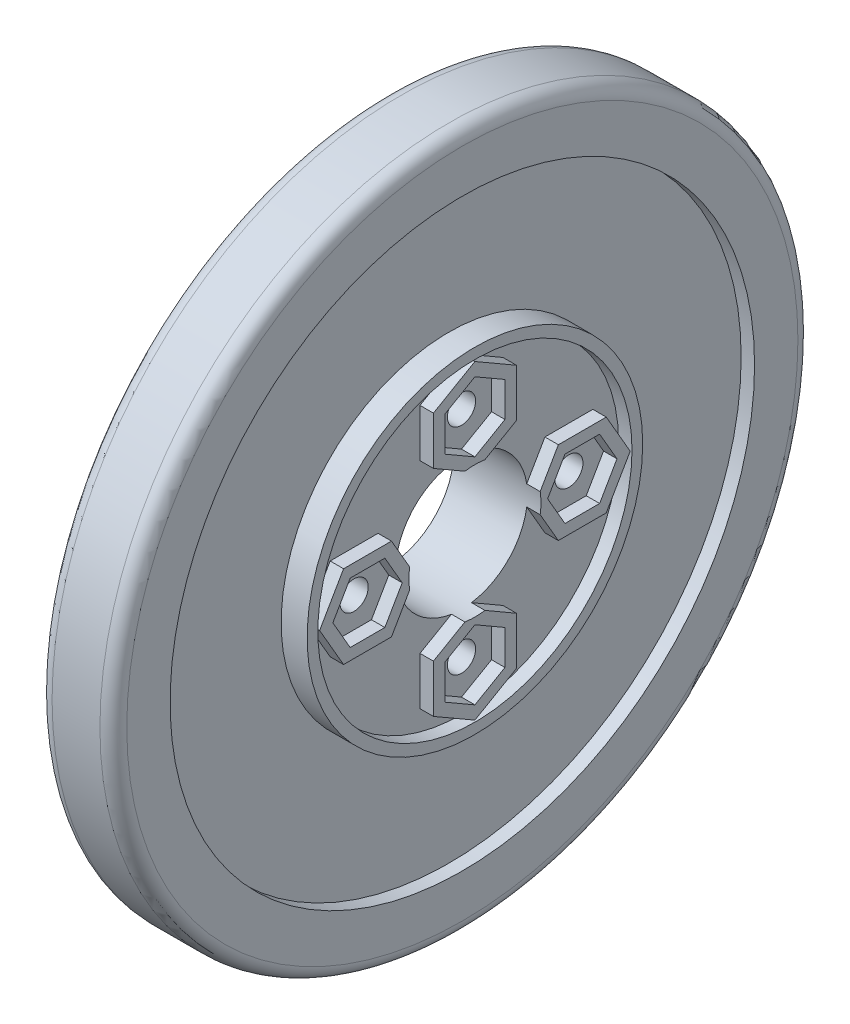
from build123d import *

# Parameters (mm, degrees)
FILLET1_R          = 1
SKETCH2_R          = 11.704122172
SKETCH2_R_2        = 1.05
CUT_EXTRUDE1_DEPTH = 1
SKETCH2_3_R        = 4.91900138
SKETCH2_3_R_2      = 1.05
CUT_EXTRUDE2_DEPTH = 38.339657272
SKETCH3_R          = 21.771584826
SKETCH3_R_2        = 12.5
CUT_EXTRUDE3_DEPTH = 1
CUT_EXTRUDE4_START = -1
SKETCH4_R          = 21.771584826
SKETCH4_R_2        = 12.5
CUT_EXTRUDE4_DEPTH = 1


with BuildPart() as part:
    # Sketch1 → Revolve1 (revolve)
    with BuildSketch(Plane(origin=(0, 0, 0), x_dir=(1, 0, 0), z_dir=(0, 1, 0))):
        Polygon((0, 0), (6.5, 0), (6.5, 12.5), (5.563387429, 12.5), (5.563387429, 26), (0, 26), align=None)
    revolve(axis=Axis((6.5, 0, 0), (-1, 0, 0)))

    # Fillet1
    fillet1_edges = [part.edges().sort_by_distance(p)[0] for p in [
        (0, 0, 26),
        (5.563387429, 0, 26),
    ]]
    fillet(fillet1_edges, radius=FILLET1_R)

    # Sketch2 → Cut-Extrude1 (cut)
    # profile 1 of 5: a face of its own
    with BuildSketch(Plane(origin=(6.5, 0, 0), x_dir=(0, 0, -1), z_dir=(1, 0, 0))):
        Circle(SKETCH2_R)
        with BuildLine():
            Line((6.215873313, -3.090198068), (4.862176877, -0.745527062))
            ThreePointArc((4.862176877, -0.745527062), (3.478259233, -3.478259233), (0.745527062, -4.862176877))
            Line((0.745527062, -4.862176877), (3.090198068, -6.215873313))
            Line((3.090198068, -6.215873313), (3.090198068, -9.784126687))
            Line((3.090198068, -9.784126687), (0, -11.568253373))
            Line((0, -11.568253373), (-3.090198068, -9.784126687))
            Line((-3.090198068, -9.784126687), (-3.090198068, -6.215873313))
            Line((-3.090198068, -6.215873313), (-0.745527062, -4.862176877))
            ThreePointArc((-0.745527062, -4.862176877), (-3.478259233, -3.478259233), (-4.862176877, -0.745527062))
            Line((-4.862176877, -0.745527062), (-6.215873313, -3.090198068))
            Line((-6.215873313, -3.090198068), (-9.784126687, -3.090198068))
            Line((-9.784126687, -3.090198068), (-11.568253373, 0))
            Line((-11.568253373, 0), (-9.784126687, 3.090198068))
            Line((-9.784126687, 3.090198068), (-6.215873313, 3.090198068))
            Line((-6.215873313, 3.090198068), (-4.862176877, 0.745527062))
            ThreePointArc((-4.862176877, 0.745527062), (-3.478259233, 3.478259233), (-0.745527062, 4.862176877))
            Line((-0.745527062, 4.862176877), (-3.090198068, 6.215873313))
            Line((-3.090198068, 6.215873313), (-3.090198068, 9.784126687))
            Line((-3.090198068, 9.784126687), (0, 11.568253373))
            Line((0, 11.568253373), (3.090198068, 9.784126687))
            Line((3.090198068, 9.784126687), (3.090198068, 6.215873313))
            Line((3.090198068, 6.215873313), (0.745527062, 4.862176877))
            ThreePointArc((0.745527062, 4.862176877), (3.478259233, 3.478259233), (4.862176877, 0.745527062))
            Line((4.862176877, 0.745527062), (6.215873313, 3.090198068))
            Line((6.215873313, 3.090198068), (9.784126687, 3.090198068))
            Line((9.784126687, 3.090198068), (11.568253373, 0))
            Line((11.568253373, 0), (9.784126687, -3.090198068))
            Line((9.784126687, -3.090198068), (6.215873313, -3.090198068))
        make_face(mode=Mode.SUBTRACT)
    # profile 2 of 5: a face of its own
    with BuildSketch(Plane(origin=(6.5, 0, 0), x_dir=(0, 0, -1), z_dir=(1, 0, 0))):
        Polygon((-2.237316109, 6.708284942), (0, 5.416569884), (2.237316109, 6.708284942), (2.237316109, 9.291715058), (0, 10.583430116), (-2.237316109, 9.291715058), align=None)
        with Locations((0, 8)):
            Circle(SKETCH2_R_2, mode=Mode.SUBTRACT)
    # profile 3 of 5: a face of its own
    with BuildSketch(Plane(origin=(6.5, 0, 0), x_dir=(0, 0, -1), z_dir=(1, 0, 0))):
        Polygon((-6.708284942, -2.237316109), (-5.416569884, 0), (-6.708284942, 2.237316109), (-9.291715058, 2.237316109), (-10.583430116, 0), (-9.291715058, -2.237316109), align=None)
        with Locations((-8, 0)):
            Circle(SKETCH2_R_2, mode=Mode.SUBTRACT)
    # profile 4 of 5: a face of its own
    with BuildSketch(Plane(origin=(6.5, 0, 0), x_dir=(0, 0, -1), z_dir=(1, 0, 0))):
        Polygon((6.708284942, 2.237316109), (5.416569884, 0), (6.708284942, -2.237316109), (9.291715058, -2.237316109), (10.583430116, 0), (9.291715058, 2.237316109), align=None)
        with Locations((8, 0)):
            Circle(SKETCH2_R_2, mode=Mode.SUBTRACT)
    # profile 5 of 5: a face of its own
    with BuildSketch(Plane(origin=(6.5, 0, 0), x_dir=(0, 0, -1), z_dir=(1, 0, 0))):
        Polygon((2.237316109, -6.708284942), (0, -5.416569884), (-2.237316109, -6.708284942), (-2.237316109, -9.291715058), (0, -10.583430116), (2.237316109, -9.291715058), align=None)
        with Locations((0, -8)):
            Circle(SKETCH2_R_2, mode=Mode.SUBTRACT)
    extrude(amount=-CUT_EXTRUDE1_DEPTH, mode=Mode.SUBTRACT)

    # Sketch2_3 → Cut-Extrude2 (cut, through all)
    with BuildSketch(Plane(origin=(6.5, 0, 0), x_dir=(0, 0, -1), z_dir=(1, 0, 0))):
        Circle(SKETCH2_3_R)
        with Locations((8, 0)):
            Circle(SKETCH2_3_R_2)
        with Locations((0, -8)):
            Circle(SKETCH2_3_R_2)
        with Locations((-8, 0)):
            Circle(SKETCH2_3_R_2)
        with Locations((0, 8)):
            Circle(SKETCH2_3_R_2)
    extrude(amount=-CUT_EXTRUDE2_DEPTH, mode=Mode.SUBTRACT)

    # Sketch3 → Cut-Extrude3 (cut)
    with BuildSketch(Plane.ZY):
        Circle(SKETCH3_R)
        Circle(SKETCH3_R_2, mode=Mode.SUBTRACT)
    extrude(amount=-CUT_EXTRUDE3_DEPTH, mode=Mode.SUBTRACT)

    # Sketch4 → Cut-Extrude4 (cut)
    with BuildSketch(Plane(origin=(5.563387429, 0, 0), x_dir=(0, 0, -1), z_dir=(1, 0, 0)).offset(CUT_EXTRUDE4_START)):
        Circle(SKETCH4_R)
        Circle(SKETCH4_R_2, mode=Mode.SUBTRACT)
    extrude(amount=CUT_EXTRUDE4_DEPTH, mode=Mode.SUBTRACT)


solid = part.part
